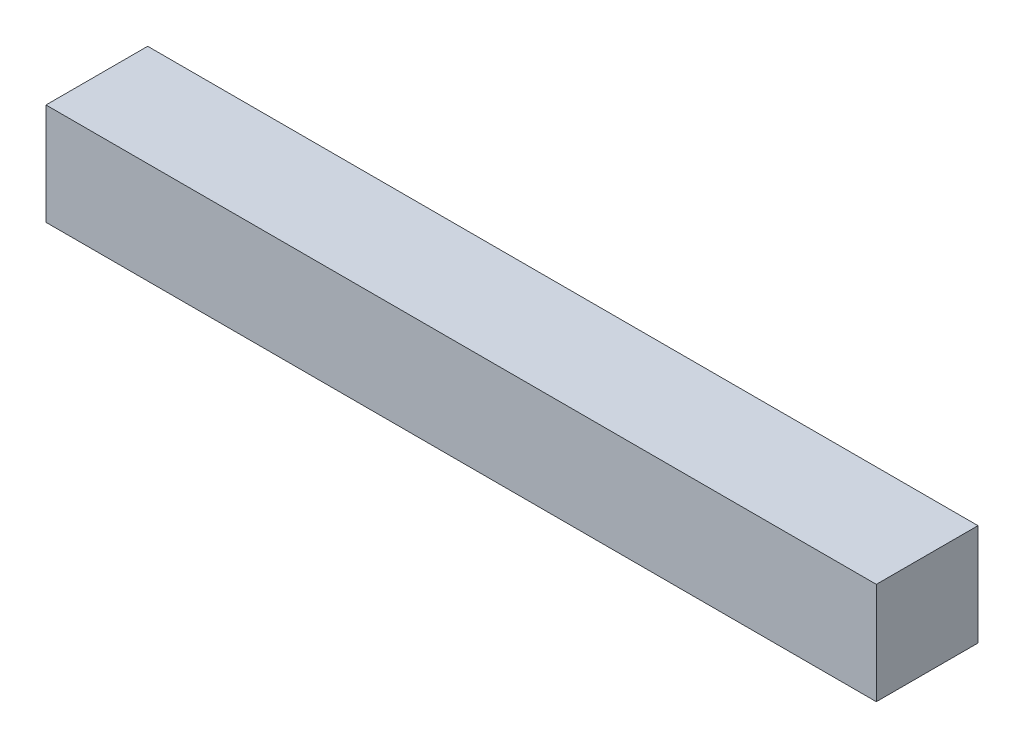
from build123d import *

# Parameters (mm, degrees)
SKETCH1_W           = 24.5
SKETCH1_H           = 3
BOSS_EXTRUDE1_DEPTH = 3


with BuildPart() as part:
    # Sketch1 → Boss-Extrude1 (new body)
    with BuildSketch(Plane(origin=(0, 0, 0), x_dir=(1, 0, 0), z_dir=(0, 1, 0))):
        with Locations((12.25, 1.5)):
            Rectangle(SKETCH1_W, SKETCH1_H)
    extrude(amount=BOSS_EXTRUDE1_DEPTH)


solid = part.part
